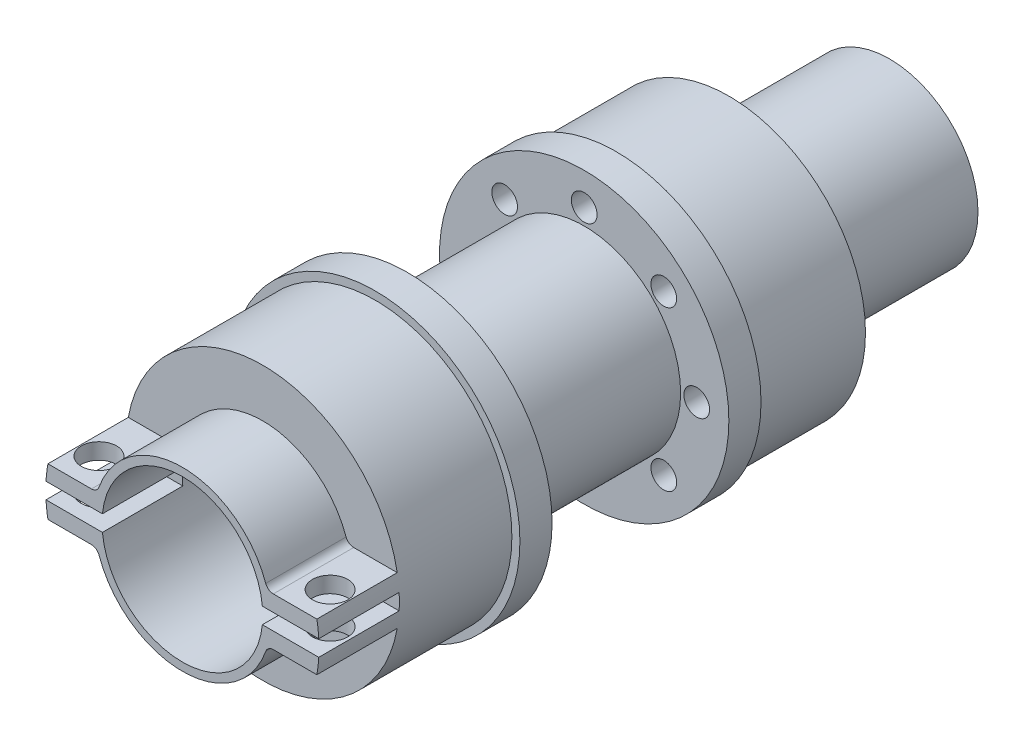
from build123d import *

# Parameters (mm, degrees)
ESQUISSE1_R                                   = 5.5
ESQUISSE1_R_2                                 = 4.5
BOSS_EXTRU_1_DEPTH                            = 10
ESQUISSE3_R                                   = 8.5
ESQUISSE3_R_2                                 = 5
BOSS_EXTRU_3_DEPTH                            = 7
ESQUISSE4_R                                   = 9
ESQUISSE4_R_2                                 = 5
BOSS_EXTRU_4_DEPTH                            = 2
ESQUISSE7_R                                   = 6
ESQUISSE7_R_2                                 = 5
BOSS_EXTRU_7_DEPTH                            = 11
ESQUISSE8_R                                   = 9
ESQUISSE8_R_2                                 = 5
BOSS_EXTRU_8_DEPTH                            = 2
ESQUISSE15_R                                  = 8.5
ESQUISSE15_R_2                                = 5
BOSS_EXTRU_9_DEPTH                            = 7
ESQUISSE16_R                                  = 5
BOSS_EXTRU_10_DEPTH                           = 5
TROU_POUR_TARAUDAGE_POUR_TROU_TARAUD_M2_D     = 1.6
TROU_POUR_TARAUDAGE_POUR_TROU_TARAUD_M2_DEPTH = 9
ENL_V_MAT_EXTRU_1_DEPTH                       = 5
D_GAGEMENT_M21_D                              = 2.2
CONG_1_R                                      = 0.5


with BuildPart() as part:
    # Esquisse1 → Boss.-Extru.1 (new body)
    with BuildSketch(Plane.XY):
        Circle(ESQUISSE1_R)
        Circle(ESQUISSE1_R_2, mode=Mode.SUBTRACT)
    extrude(amount=BOSS_EXTRU_1_DEPTH)

    # Esquisse3 → Boss.-Extru.3 (add)
    with BuildSketch(Plane.XY.offset(10)):
        Circle(ESQUISSE3_R)
        Circle(ESQUISSE3_R_2, mode=Mode.SUBTRACT)
    extrude(amount=BOSS_EXTRU_3_DEPTH)

    # Esquisse4 → Boss.-Extru.4 (add)
    with BuildSketch(Plane.XY.offset(17)):
        Circle(ESQUISSE4_R)
        Circle(ESQUISSE4_R_2, mode=Mode.SUBTRACT)
    extrude(amount=BOSS_EXTRU_4_DEPTH)

    # Esquisse7 → Boss.-Extru.7 (add)
    with BuildSketch(Plane.XY.offset(19)):
        Circle(ESQUISSE7_R)
        Circle(ESQUISSE7_R_2, mode=Mode.SUBTRACT)
    extrude(amount=BOSS_EXTRU_7_DEPTH)

    # Esquisse8 → Boss.-Extru.8 (add)
    with BuildSketch(Plane.XY.offset(30)):
        Circle(ESQUISSE8_R)
        Circle(ESQUISSE8_R_2, mode=Mode.SUBTRACT)
    extrude(amount=BOSS_EXTRU_8_DEPTH)

    # Esquisse15 → Boss.-Extru.9 (add)
    with BuildSketch(Plane.XY.offset(32)):
        Circle(ESQUISSE15_R)
        Circle(ESQUISSE15_R_2, mode=Mode.SUBTRACT)
    extrude(amount=BOSS_EXTRU_9_DEPTH)

    # Esquisse16 → Boss.-Extru.10 (add)
    with BuildSketch(Plane.XY.offset(39)):
        with BuildLine():
            Line((-5.291502622, 1.5), (-8.366600265, 1.5))
            ThreePointArc((-8.366600265, 1.5), (-8.5, 0), (-8.366600265, -1.5))
            Line((-8.366600265, -1.5), (-5.291502622, -1.5))
            ThreePointArc((-5.291502622, -1.5), (0, -5.5), (5.291502622, -1.5))
            Line((5.291502622, -1.5), (8.366600265, -1.5))
            ThreePointArc((8.366600265, -1.5), (8.5, 0), (8.366600265, 1.5))
            Line((8.366600265, 1.5), (5.291502622, 1.5))
            ThreePointArc((5.291502622, 1.5), (0, 5.5), (-5.291502622, 1.5))
        make_face()
        Circle(ESQUISSE16_R, mode=Mode.SUBTRACT)
    extrude(amount=BOSS_EXTRU_10_DEPTH)

    # Trou pour taraudage pour trou taraudé M21
    with Locations(Plane(origin=(0, 0, 10), x_dir=(-1, 0, 0), z_dir=(0, 0, -1))):
        with Locations((-7, 0), (-4.949747468, 4.949747468), (0, 7), (4.949747468, 4.949747468), (7, 0), (4.949747468, -4.949747468), (0, -7), (-4.949747468, -4.949747468), (0, 0)):
            Hole(TROU_POUR_TARAUDAGE_POUR_TROU_TARAUD_M2_D / 2, depth=TROU_POUR_TARAUDAGE_POUR_TROU_TARAUD_M2_DEPTH)

    # Esquisse17 → Enlèv. mat.-Extru.1 (cut)
    with BuildSketch(Plane.XY.offset(44)):
        with BuildLine():
            Line((-4.974937186, 0.5), (-8.485281374, 0.5))
            ThreePointArc((-8.485281374, 0.5), (-8.5, 0), (-8.485281374, -0.5))
            Line((-8.485281374, -0.5), (-4.974937186, -0.5))
            ThreePointArc((-4.974937186, -0.5), (-5, 0), (-4.974937186, 0.5))
        make_face()
        with BuildLine():
            Line((8.485281374, 0.5), (4.974937186, 0.5))
            ThreePointArc((4.974937186, 0.5), (5, 0), (4.974937186, -0.5))
            Line((4.974937186, -0.5), (8.485281374, -0.5))
            ThreePointArc((8.485281374, -0.5), (8.5, 0), (8.485281374, 0.5))
        make_face()
    extrude(amount=-ENL_V_MAT_EXTRU_1_DEPTH, mode=Mode.SUBTRACT)

    # Dégagement M21 (through all)
    with Locations(Plane(origin=(0, 1.5, 0), x_dir=(1, 0, 0), z_dir=(0, 1, 0))):
        with Locations((7.191502622, -42), (-7.191502622, -42)):
            Hole(D_GAGEMENT_M21_D / 2)

    # Congé1
    cong_1_edges = [part.edges().sort_by_distance(p)[0] for p in [
        (5.291502622, 1.5, 41.5),
        (-5.291502622, 1.5, 41.5),
        (-5.291502622, -1.5, 41.5),
        (5.291502622, -1.5, 41.5),
    ]]
    fillet(cong_1_edges, radius=CONG_1_R)


solid = part.part
